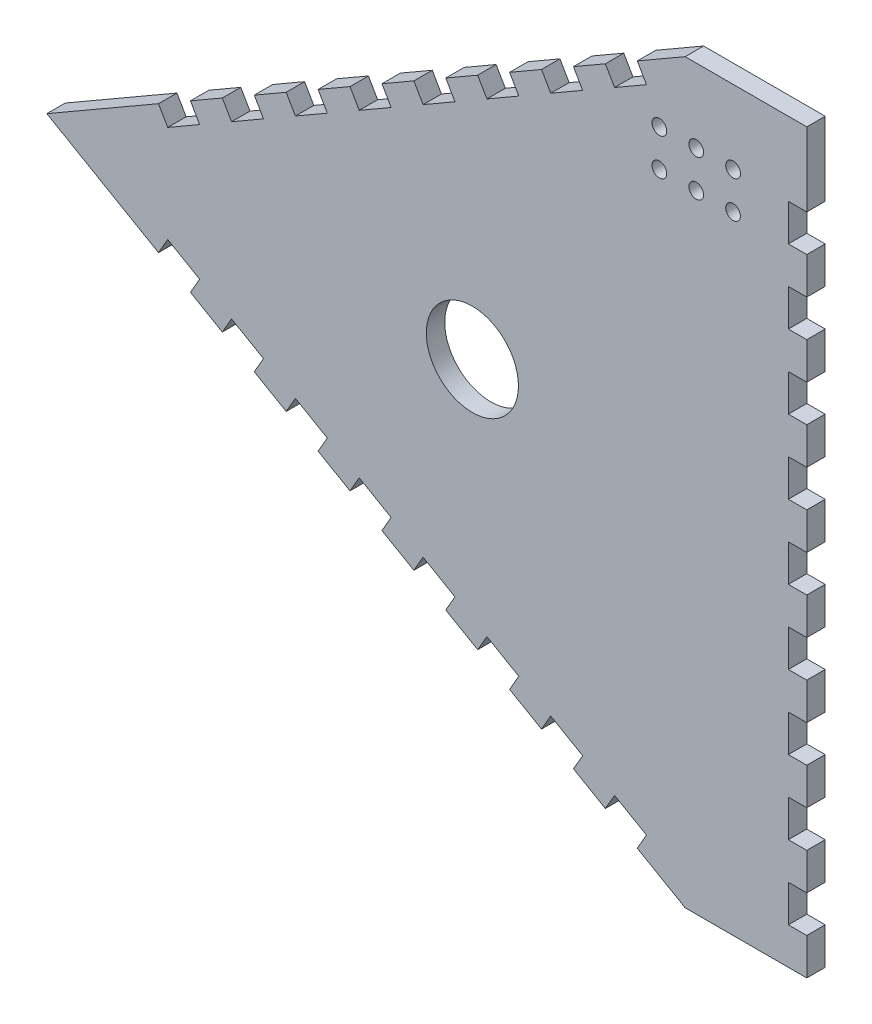
from build123d import *

# Parameters (mm, degrees)
SKETCH1_R               = 2
BOSS_EXTRUDE1_DEPTH     = 5
SKETCH3_R               = 12.5
SKETCH3_W               = 5
SKETCH3_H               = 10
CUT_EXTRUDE5_DEPTH      = 1
CUT_EXTRUDE5_DEPTH_BACK = 6


with BuildPart() as part:
    # Sketch1 → Boss-Extrude1 (new body)
    with BuildSketch(Plane.XY):
        Polygon((2.5, -200), (2.5, 0), (-2.5, 0), (-30.5, 0), (-203.705080757, -100), (-30.5, -200), align=None)
        with Locations((-37.5, -30)):
            Circle(SKETCH1_R, mode=Mode.SUBTRACT)
        with Locations((-27.5, -30)):
            Circle(SKETCH1_R, mode=Mode.SUBTRACT)
        with Locations((-17.5, -30)):
            Circle(SKETCH1_R, mode=Mode.SUBTRACT)
        with Locations((-37.5, -20)):
            Circle(SKETCH1_R, mode=Mode.SUBTRACT)
        with Locations((-27.5, -20)):
            Circle(SKETCH1_R, mode=Mode.SUBTRACT)
        with Locations((-17.5, -20)):
            Circle(SKETCH1_R, mode=Mode.SUBTRACT)
    extrude(amount=BOSS_EXTRUDE1_DEPTH)

    # Sketch3 → Cut-Extrude5 (cut, two sides)
    with BuildSketch(Plane.XY.offset(5)) as cut_extrude5_sk:
        with Locations((-88.235026919, -100)):
            Circle(SKETCH3_R)
        Polygon((-121.432667397, -52.5), (-112.77241336, -47.5), (-110.27241336, -51.830127019), (-118.932667397, -56.830127019), align=None)
        Polygon((-101.612159322, -46.830127019), (-104.112159322, -42.5), (-95.451905284, -37.5), (-92.951905284, -41.830127019), align=None)
        Polygon((-84.291651246, -36.830127019), (-86.791651246, -32.5), (-78.131397208, -27.5), (-75.631397208, -31.830127019), align=None)
        Polygon((-66.97114317, -26.830127019), (-69.47114317, -22.5), (-60.810889132, -17.5), (-58.310889132, -21.830127019), align=None)
        Polygon((-49.650635095, -16.830127019), (-52.150635095, -12.5), (-43.490381057, -7.5), (-40.990381057, -11.830127019), align=None)
        Polygon((-136.253175473, -66.830127019), (-138.753175473, -62.5), (-130.092921435, -57.5), (-127.592921435, -61.830127019), align=None)
        Polygon((-153.573683549, -76.830127019), (-156.073683549, -72.5), (-147.413429511, -67.5), (-144.913429511, -71.830127019), align=None)
        Polygon((-170.894191624, -86.830127019), (-173.394191624, -82.5), (-164.733937587, -77.5), (-162.233937587, -81.830127019), align=None)
        Polygon((-112.77241336, -152.5), (-110.27241336, -148.169872981), (-118.932667397, -143.169872981), (-121.432667397, -147.5), align=None)
        Polygon((-173.394191624, -117.5), (-164.733937587, -122.5), (-162.233937587, -118.169872981), (-170.894191624, -113.169872981), align=None)
        Polygon((-156.073683549, -127.5), (-147.413429511, -132.5), (-144.913429511, -128.169872981), (-153.573683549, -123.169872981), align=None)
        Polygon((-138.753175473, -137.5), (-130.092921435, -142.5), (-127.592921435, -138.169872981), (-136.253175473, -133.169872981), align=None)
        Polygon((-52.150635095, -187.5), (-43.490381057, -192.5), (-40.990381057, -188.169872981), (-49.650635095, -183.169872981), align=None)
        Polygon((-69.47114317, -177.5), (-60.810889132, -182.5), (-58.310889132, -178.169872981), (-66.97114317, -173.169872981), align=None)
        Polygon((-86.791651246, -167.5), (-78.131397208, -172.5), (-75.631397208, -168.169872981), (-84.291651246, -163.169872981), align=None)
        Polygon((-104.112159322, -157.5), (-95.451905284, -162.5), (-92.951905284, -158.169872981), (-101.612159322, -153.169872981), align=None)
        with Locations((0, -85)):
            Rectangle(SKETCH3_W, SKETCH3_H)
        with Locations((0, -105)):
            Rectangle(SKETCH3_W, SKETCH3_H)
        with Locations((0, -65)):
            Rectangle(SKETCH3_W, SKETCH3_H)
        with Locations((0, -45)):
            Rectangle(SKETCH3_W, SKETCH3_H)
        with Locations((0, -25)):
            Rectangle(SKETCH3_W, SKETCH3_H)
        with Locations((0, -125)):
            Rectangle(SKETCH3_W, SKETCH3_H)
        with Locations((0, -145)):
            Rectangle(SKETCH3_W, SKETCH3_H)
        with Locations((0, -165)):
            Rectangle(SKETCH3_W, SKETCH3_H)
        with Locations((0, -185)):
            Rectangle(SKETCH3_W, SKETCH3_H)
    extrude(amount=CUT_EXTRUDE5_DEPTH, mode=Mode.SUBTRACT)
    extrude(cut_extrude5_sk.sketch, amount=-CUT_EXTRUDE5_DEPTH_BACK, mode=Mode.SUBTRACT)


solid = part.part
